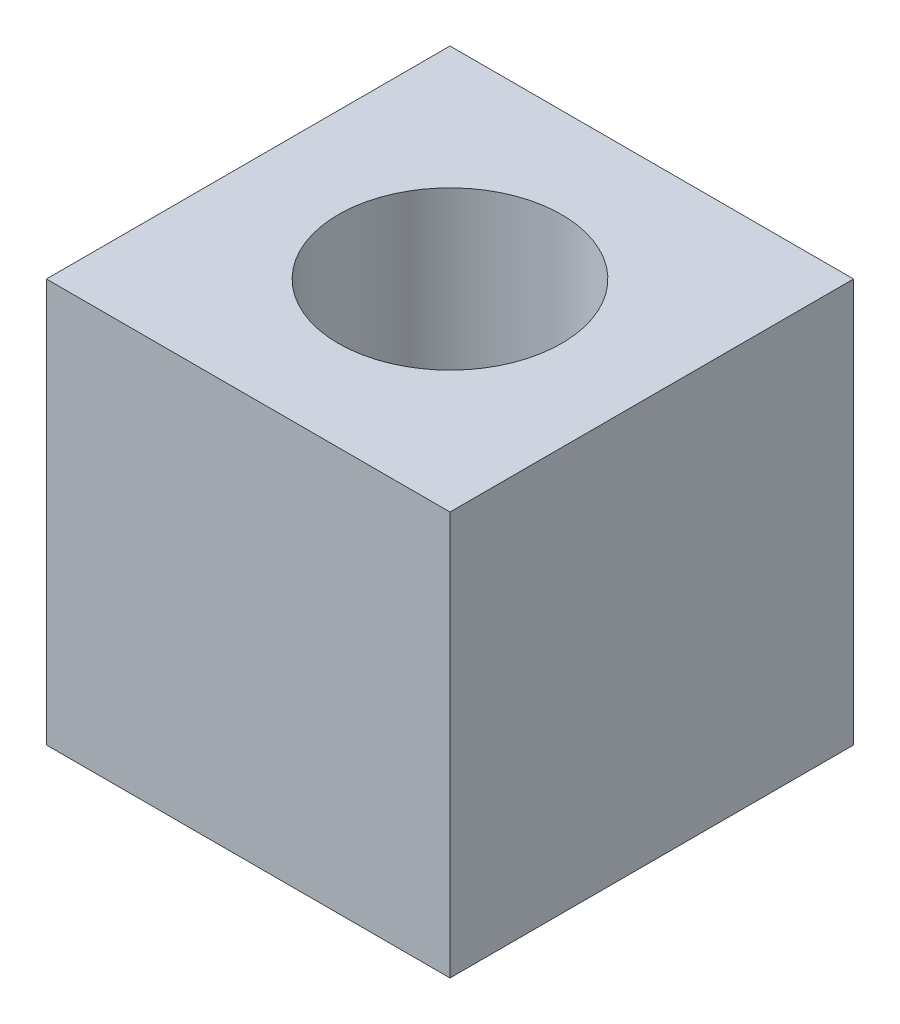
from build123d import *

# Parameters (mm, degrees)
ESQUISSE1_W             = 15
ESQUISSE1_H             = 15
ESQUISSE1_R             = 4.15
BOSS_EXTRU_1_DEPTH      = 15
ESQUISSE2_R             = 2.15
ENL_V_MAT_EXTRU_1_DEPTH = 8.5


with BuildPart() as part:
    # Esquisse1 → Boss.-Extru.1 (new body)
    with BuildSketch(Plane(origin=(0, 0, 0), x_dir=(1, 0, 0), z_dir=(0, 1, 0))):
        Rectangle(ESQUISSE1_W, ESQUISSE1_H)
        Circle(ESQUISSE1_R, mode=Mode.SUBTRACT)
    extrude(amount=BOSS_EXTRU_1_DEPTH)

    # Esquisse2 → Enlèv. mat.-Extru.1 (cut, through all)
    with BuildSketch(Plane.XY):
        with Locations((0, 7.5)):
            Circle(ESQUISSE2_R)
    extrude(amount=-ENL_V_MAT_EXTRU_1_DEPTH, mode=Mode.SUBTRACT)


solid = part.part
